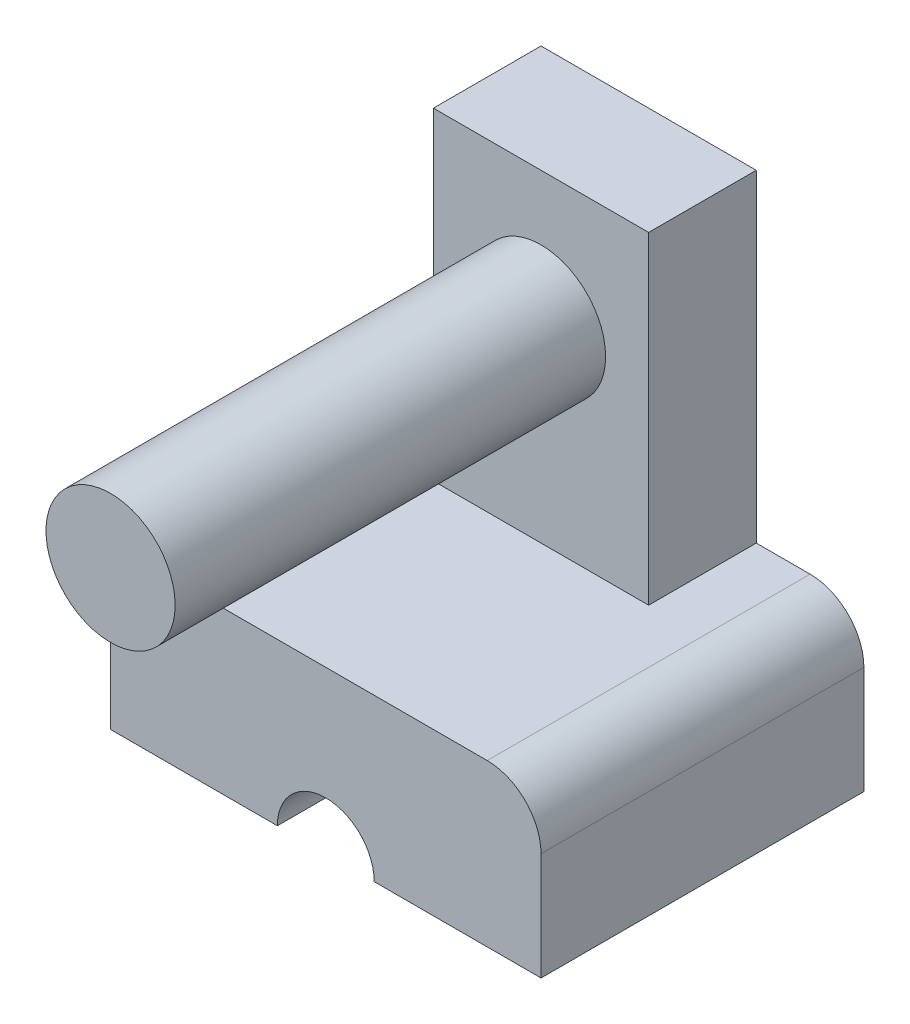
from build123d import *

# Parameters (mm, degrees)
ESQUISSE1_W             = 20
ESQUISSE1_H             = 30
BOSS_EXTRU_1_DEPTH      = 10
ESQUISSE2_R             = 6
BOSS_EXTRU_2_DEPTH      = 40
ESQUISSE3_W             = 40
ESQUISSE3_H             = 30
BOSS_EXTRU_3_DEPTH      = 15
ESQUISSE4_R             = 4.5
ENL_V_MAT_EXTRU_1_DEPTH = 55
ENL_V_MAT_EXTRU_3_DEPTH = 55


with BuildPart() as part:
    # Esquisse1 → Boss.-Extru.1 (new body)
    with BuildSketch(Plane.XY):
        with Locations((-10, 15)):
            Rectangle(ESQUISSE1_W, ESQUISSE1_H)
    extrude(amount=BOSS_EXTRU_1_DEPTH)

    # Esquisse2 → Boss.-Extru.2 (add)
    with BuildSketch(Plane.XY.offset(10)):
        with Locations((-10, 18)):
            Circle(ESQUISSE2_R)
    extrude(amount=BOSS_EXTRU_2_DEPTH)

    # Esquisse3 → Boss.-Extru.3 (add)
    with BuildSketch(Plane.XZ):
        with Locations((-10, 15)):
            Rectangle(ESQUISSE3_W, ESQUISSE3_H)
    extrude(amount=BOSS_EXTRU_3_DEPTH)

    # Esquisse4 → Enlèv. mat.-Extru.1 (cut)
    with BuildSketch(Plane(origin=(0, 0, 0), x_dir=(-1, 0, 0), z_dir=(0, 0, -1))):
        with Locations((10, -15)):
            Circle(ESQUISSE4_R)
    extrude(amount=-ENL_V_MAT_EXTRU_1_DEPTH, mode=Mode.SUBTRACT)

    # Esquisse5 → Enlèv. mat.-Extru.3 (cut)
    with BuildSketch(Plane(origin=(0, 0, 0), x_dir=(-1, 0, 0), z_dir=(0, 0, -1))):
        with BuildLine():
            Line((30, 0), (25, 0))
            ThreePointArc((25, 0), (28.535533906, -1.464466094), (30, -5))
            Line((30, -5), (30, 0))
        make_face()
        with BuildLine():
            Line((-10, 0), (-10, -5))
            ThreePointArc((-10, -5), (-8.535533906, -1.464466094), (-5, 0))
            Line((-5, 0), (-10, 0))
        make_face()
    extrude(amount=-ENL_V_MAT_EXTRU_3_DEPTH, mode=Mode.SUBTRACT)


solid = part.part
